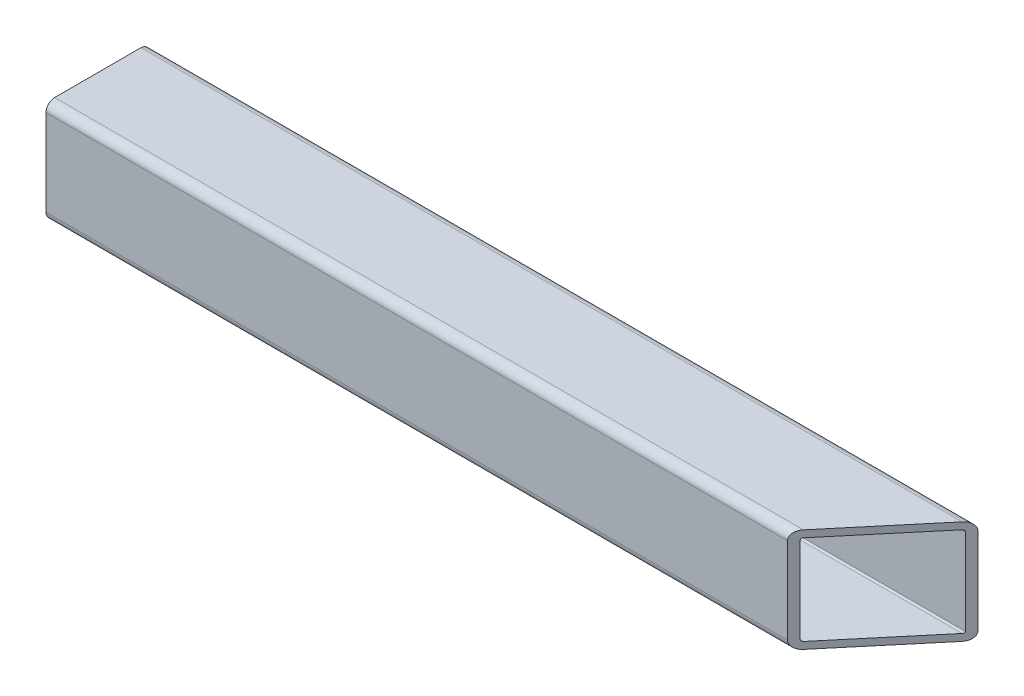
from build123d import *

# Parameters (mm, degrees)
EXTRUDE_THIN1_DEPTH     = 152.4
CUT_EXTRUDE1_DEPTH      = 1
CUT_EXTRUDE1_DEPTH_BACK = 39.1


with BuildPart() as part:
    # Sketch1 → Extrude-Thin1 (new body, symmetric)
    with BuildSketch(Plane(origin=(0, 0, 0), x_dir=(0, 0, -1), z_dir=(1, 0, 0))):
        with BuildLine():
            Line((-15.875, 19.05), (15.875, 19.05))
            ThreePointArc((15.875, 19.05), (18.12006403, 18.12006403), (19.05, 15.875))
            Line((19.05, 15.875), (19.05, -15.875))
            ThreePointArc((19.05, -15.875), (18.12006403, -18.12006403), (15.875, -19.05))
            Line((15.875, -19.05), (-15.875, -19.05))
            ThreePointArc((-15.875, -19.05), (-18.12006403, -18.12006403), (-19.05, -15.875))
            Line((-19.05, -15.875), (-19.05, 15.875))
            ThreePointArc((-19.05, 15.875), (-18.12006403, 18.12006403), (-15.875, 19.05))
        make_face()
        with BuildLine():
            Line((-15.875, 16.51), (15.875, 16.51))
            ThreePointArc((15.875, 16.51), (16.324012806, 16.324012806), (16.51, 15.875))
            Line((16.51, 15.875), (16.51, -15.875))
            ThreePointArc((16.51, -15.875), (16.324012806, -16.324012806), (15.875, -16.51))
            Line((15.875, -16.51), (-15.875, -16.51))
            ThreePointArc((-15.875, -16.51), (-16.324012806, -16.324012806), (-16.51, -15.875))
            Line((-16.51, -15.875), (-16.51, 15.875))
            ThreePointArc((-16.51, 15.875), (-16.324012806, 16.324012806), (-15.875, 16.51))
        make_face(mode=Mode.SUBTRACT)
    extrude(amount=EXTRUDE_THIN1_DEPTH, both=True)

    # Sketch3 → Cut-Extrude1 (cut, two sides)
    with BuildSketch(Plane(origin=(0, 19.05, 0), x_dir=(1, 0, 0), z_dir=(0, 1, 0))) as cut_extrude1_sk:
        Polygon((553.720613364, 497.325282758), (152.4, 19.05), (120.430304052, -19.05), (-280.890309312, -497.325282758), (675.660256205, -1299.966509486), (1510.271178881, -305.315943969), align=None)
    extrude(amount=CUT_EXTRUDE1_DEPTH, mode=Mode.SUBTRACT)
    extrude(cut_extrude1_sk.sketch, amount=-CUT_EXTRUDE1_DEPTH_BACK, mode=Mode.SUBTRACT)


solid = part.part
